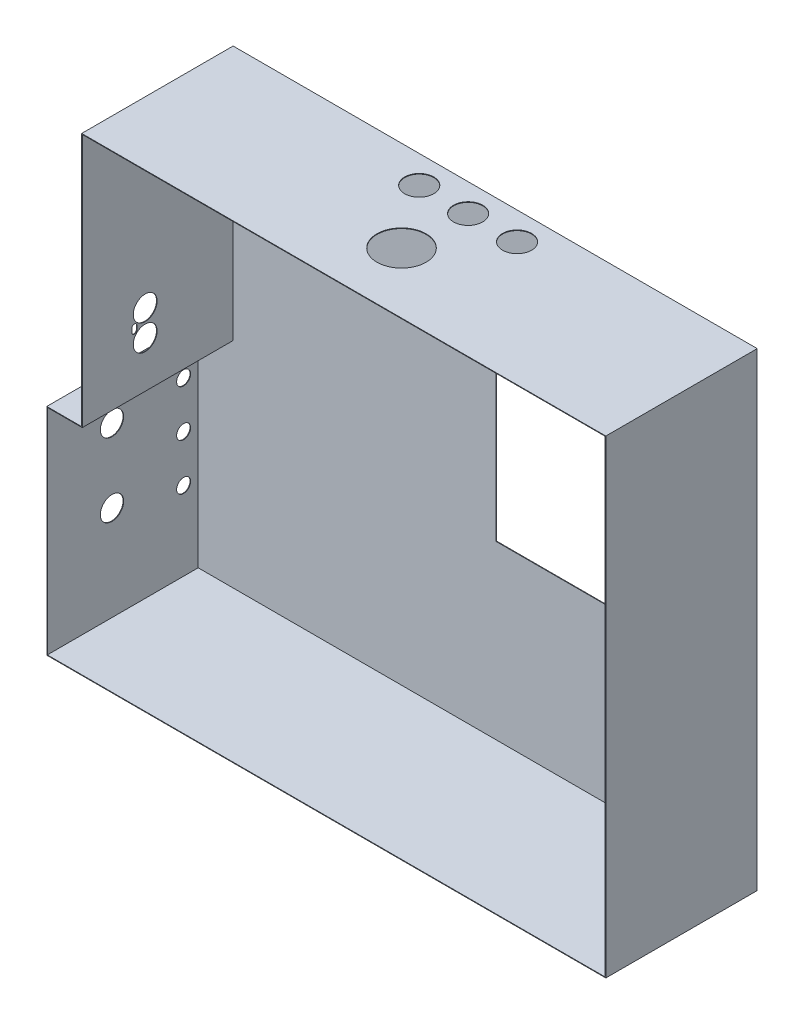
from build123d import *

# Parameters (mm, degrees)
DODANIE_WYCI_GNI_CIE1_DEPTH = 130
SKORUPA1_T                  = -0.5
WYTNIJ_WYCI_GNI_CIE1_REACH  = 132
SZKIC2_W                    = 206
SZKIC2_H                    = 132
SZKIC4_R                    = 2
WYTNIJ_WYCI_GNI_CIE2_DEPTH  = 10
SZKIC5_R                    = 21.15
SZKIC5_R_2                  = 12.5
WYTNIJ_WYCI_GNI_CIE3_DEPTH  = 10
SZKIC6_R                    = 10
SZKIC6_R_2                  = 6
WYTNIJ_WYCI_GNI_CIE4_DEPTH  = 10
SZKIC7_R                    = 10.25
WYTNIJ_WYCI_GNI_CIE5_DEPTH  = 10


with BuildPart() as part:
    # Szkic1 → Dodanie-wyciągnięcie1 (new body)
    with BuildSketch(Plane.XY):
        Polygon((0, 403), (0, 185), (-30, 185), (-30, 0), (450, 0), (450, 403), align=None)
    extrude(amount=DODANIE_WYCI_GNI_CIE1_DEPTH)

    # Skorupa1
    skorupa1_openings = [part.faces().sort_by_distance(p)[0] for p in [
        (140, 196, 130),
    ]]
    offset(amount=SKORUPA1_T, openings=skorupa1_openings, kind=Kind.INTERSECTION)

    # Szkic2 → Wytnij-wyciągnięcie1 (cut, up to next)
    with BuildSketch(Plane(origin=(0, 0, 0), x_dir=(-1, 0, 0), z_dir=(0, 0, -1)), mode=Mode.PRIVATE) as wytnij_wyci_gni_cie1_sk1:
        with Locations((-329, 214)):
            Rectangle(SZKIC2_W, SZKIC2_H)
    wytnij_wyci_gni_cie1_tool1 = extrude(wytnij_wyci_gni_cie1_sk1.sketch, amount=-WYTNIJ_WYCI_GNI_CIE1_REACH, mode=Mode.PRIVATE) & part.part
    add(wytnij_wyci_gni_cie1_tool1.solids().sort_by_distance((329, 214, 0))[0], mode=Mode.SUBTRACT)

    # Szkic4 → Wytnij-wyciągnięcie2 (cut)
    with BuildSketch(Plane(origin=(0, 0, 0), x_dir=(-1, 0, 0), z_dir=(0, 0, -1))):
        with Locations((-114.4, 386.6)):
            Circle(SZKIC4_R)
        with Locations((-74.7, 365.2)):
            Circle(SZKIC4_R)
        with Locations((-74.7, 335.2)):
            Circle(SZKIC4_R)
        with Locations((-114.4, 356.6)):
            Circle(SZKIC4_R)
        with Locations((-74.7, 305.2)):
            Circle(SZKIC4_R)
        with Locations((-114.4, 326.6)):
            Circle(SZKIC4_R)
    extrude(amount=-WYTNIJ_WYCI_GNI_CIE2_DEPTH, mode=Mode.SUBTRACT)

    # Szkic5 → Wytnij-wyciągnięcie3 (cut)
    with BuildSketch(Plane(origin=(0, 403, 0), x_dir=(1, 0, 0), z_dir=(0, 1, 0))):
        with Locations((222.5, -77.9)):
            Circle(SZKIC5_R)
        with Locations((225.5, -23.7)):
            Circle(SZKIC5_R_2)
        with Locations((267.5, -23.7)):
            Circle(SZKIC5_R_2)
        with Locations((183.5, -23.7)):
            Circle(SZKIC5_R_2)
    extrude(amount=-WYTNIJ_WYCI_GNI_CIE3_DEPTH, mode=Mode.SUBTRACT)

    # Szkic6 → Wytnij-wyciągnięcie4 (cut)
    with BuildSketch(Plane.ZY.offset(30)):
        with Locations((74.5, 145)):
            Circle(SZKIC6_R)
        with Locations((74.5, 82)):
            Circle(SZKIC6_R)
        with Locations((13, 148)):
            Circle(SZKIC6_R_2)
        with Locations((13, 108)):
            Circle(SZKIC6_R_2)
        with Locations((13, 68)):
            Circle(SZKIC6_R_2)
    extrude(amount=-WYTNIJ_WYCI_GNI_CIE4_DEPTH, mode=Mode.SUBTRACT)

    # Szkic7 → Wytnij-wyciągnięcie5 (cut)
    with BuildSketch(Plane(origin=(0.5, 0, 0), x_dir=(0, 0, -1), z_dir=(1, 0, 0))):
        with Locations((-76, 224.23)):
            Circle(SZKIC7_R)
        with Locations((-76, 246.58)):
            Circle(SZKIC7_R)
        with BuildLine():
            Line((-87.5, 233.905), (-87.5, 236.905))
            ThreePointArc((-87.5, 236.905), (-85.25, 239.155), (-83, 236.905))
            Line((-83, 236.905), (-83, 233.905))
            ThreePointArc((-83, 233.905), (-85.25, 231.655), (-87.5, 233.905))
        make_face()
    extrude(amount=-WYTNIJ_WYCI_GNI_CIE5_DEPTH, mode=Mode.SUBTRACT)


solid = part.part
